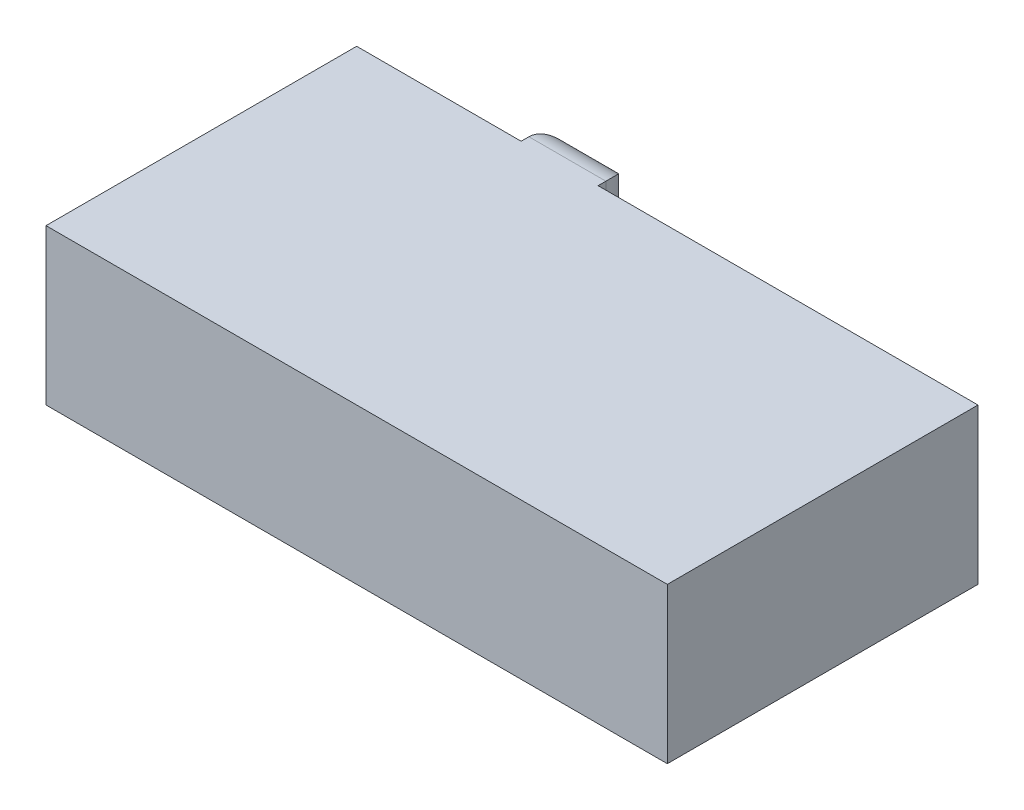
from build123d import *

# Parameters (mm, degrees)
SKETCH1_W           = 20.32
SKETCH1_H           = 10.16
BOSS_EXTRUDE1_DEPTH = 5.08
SKETCH3_W           = 2.516713444
SKETCH3_H           = 5.08
BOSS_EXTRUDE2_DEPTH = 1.27
FILLET1_R           = 1.016


with BuildPart() as part:
    # Sketch1 → Boss-Extrude1 (new body)
    with BuildSketch(Plane(origin=(0, 0, 0), x_dir=(1, 0, 0), z_dir=(0, 1, 0))):
        with Locations((10.16, 5.08)):
            Rectangle(SKETCH1_W, SKETCH1_H)
    extrude(amount=BOSS_EXTRUDE1_DEPTH)

    # Sketch3 → Boss-Extrude2 (add)
    with BuildSketch(Plane(origin=(0, 0, -10.16), x_dir=(-1, 0, 0), z_dir=(0, 0, -1))):
        with Locations((-6.637688848, 2.54)):
            Rectangle(SKETCH3_W, SKETCH3_H)
    extrude(amount=BOSS_EXTRUDE2_DEPTH)

    # Fillet1
    fillet1_edges = [part.edges().sort_by_distance(p)[0] for p in [
        (6.637688848, 0, -11.43),
        (5.379332126, 2.54, -11.43),
        (6.637688848, 5.08, -11.43),
        (7.89604557, 2.54, -11.43),
    ]]
    fillet(fillet1_edges, radius=FILLET1_R)


solid = part.part
